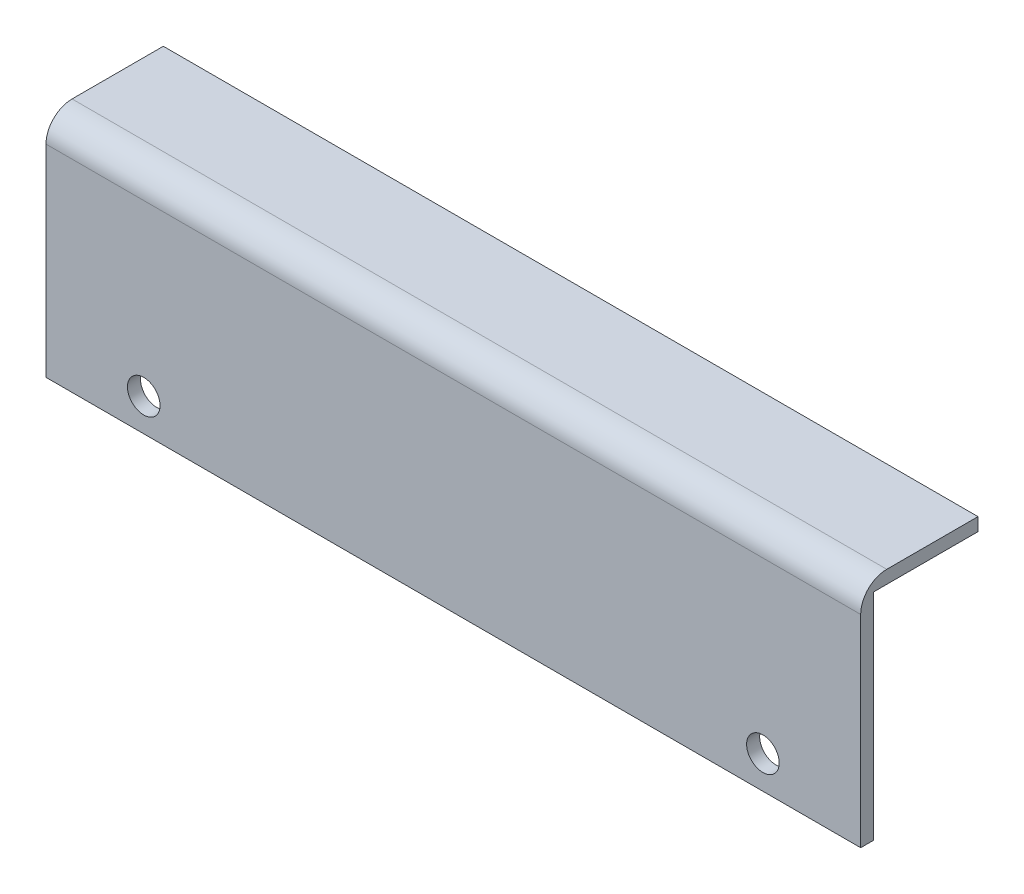
from build123d import *

# Parameters (mm, degrees)
BOSS_EXTRUDE1_DEPTH = 125
FILLET1_R           = 4
SKETCH2_R           = 2.5
CUT_EXTRUDE1_DEPTH  = 125


with BuildPart() as part:
    # Sketch1 → Boss-Extrude1 (new body)
    with BuildSketch(Plane(origin=(0, 0, 0), x_dir=(0, 0, -1), z_dir=(1, 0, 0))):
        Polygon((1.141646312, 16.786775831), (17.141646312, 16.786775831), (17.141646312, 18.786775831), (-0.858353688, 18.786775831), (-0.858353688, -16.213224169), (1.141646312, -16.213224169), align=None)
    extrude(amount=BOSS_EXTRUDE1_DEPTH)

    # Fillet1
    fillet1_edges = [part.edges().sort_by_distance(p)[0] for p in [
        (62.5, 18.786775831, 0.858353688),
    ]]
    fillet(fillet1_edges, radius=FILLET1_R)

    # Sketch2 → Cut-Extrude1 (cut)
    with BuildSketch(Plane(origin=(0, 0, -1.141646312), x_dir=(-1, 0, 0), z_dir=(0, 0, -1))):
        with Locations((-110, -11.213224169)):
            Circle(SKETCH2_R)
        with Locations((-15, -11.213224169)):
            Circle(SKETCH2_R)
    extrude(amount=-CUT_EXTRUDE1_DEPTH, mode=Mode.SUBTRACT)


solid = part.part
